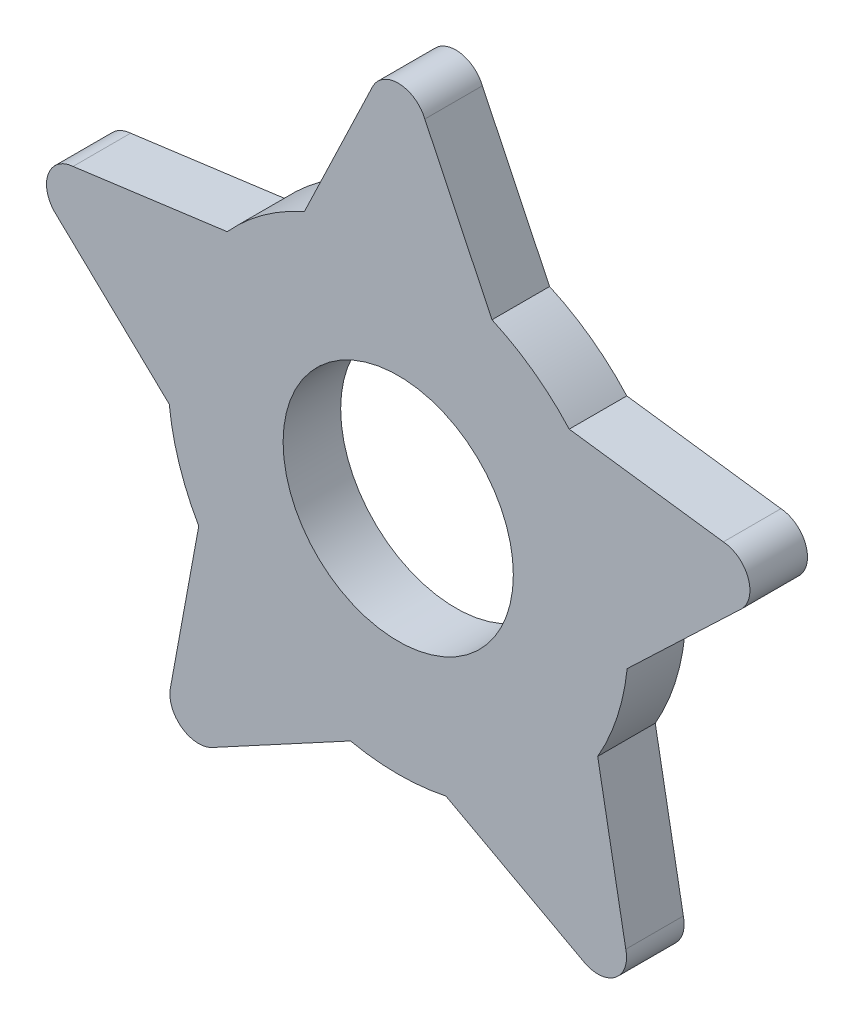
from build123d import *

# Parameters (mm, degrees)
SKETCH1_R           = 2
BOSS_EXTRUDE1_DEPTH = 1
SCALE1_SCALE        = 1.1


with BuildPart() as part:
    # Sketch1 → Boss-Extrude1 (new body)
    with BuildSketch(Plane.XY):
        with BuildLine():
            Line((-0.462098351, 6.089690496), (-1.629279619, 3.653142199))
            ThreePointArc((-1.629279619, 3.653142199), (-2.351141009, 3.236067977), (-2.970869602, 2.67842002))
            Line((-2.970869602, 2.67842002), (-5.648843585, 2.321299502))
            ThreePointArc((-5.648843585, 2.321299502), (-6.085555848, 1.977316958), (-5.934436072, 1.442336206))
            Line((-5.934436072, 1.442336206), (-3.977819784, -0.420653976))
            ThreePointArc((-3.977819784, -0.420653976), (-3.804226065, -1.236067977), (-3.465378009, -1.99778759))
            Line((-3.465378009, -1.99778759), (-3.953275684, -4.655048506))
            ThreePointArc((-3.953275684, -4.655048506), (-3.761080354, -5.176683001), (-3.205584845, -5.198277698))
            Line((-3.205584845, -5.198277698), (-0.829148209, -3.913120653))
            ThreePointArc((-0.829148209, -3.913120653), (0, -4), (0.829148209, -3.913120653))
            Line((0.829148209, -3.913120653), (3.205584845, -5.198277698))
            ThreePointArc((3.205584845, -5.198277698), (3.761080354, -5.176683001), (3.953275684, -4.655048506))
            Line((3.953275684, -4.655048506), (3.465378009, -1.99778759))
            ThreePointArc((3.465378009, -1.99778759), (3.804226065, -1.236067977), (3.977819784, -0.420653976))
            Line((3.977819784, -0.420653976), (5.934436072, 1.442336206))
            ThreePointArc((5.934436072, 1.442336206), (6.085555848, 1.977316958), (5.648843585, 2.321299502))
            Line((5.648843585, 2.321299502), (2.970869602, 2.67842002))
            ThreePointArc((2.970869602, 2.67842002), (2.351141009, 3.236067977), (1.629279619, 3.653142199))
            Line((1.629279619, 3.653142199), (0.462098351, 6.089690496))
            ThreePointArc((0.462098351, 6.089690496), (0, 6.398732088), (-0.462098351, 6.089690496))
        make_face()
        Circle(SKETCH1_R, mode=Mode.SUBTRACT)
    extrude(amount=BOSS_EXTRUDE1_DEPTH)


with BuildPart() as part_1:
    # Scale1: scaled about (0, 0, 0.5)
    add(part.part.scale(SCALE1_SCALE).moved(Location((0, 0, -0.05))))


solid = part_1.part
